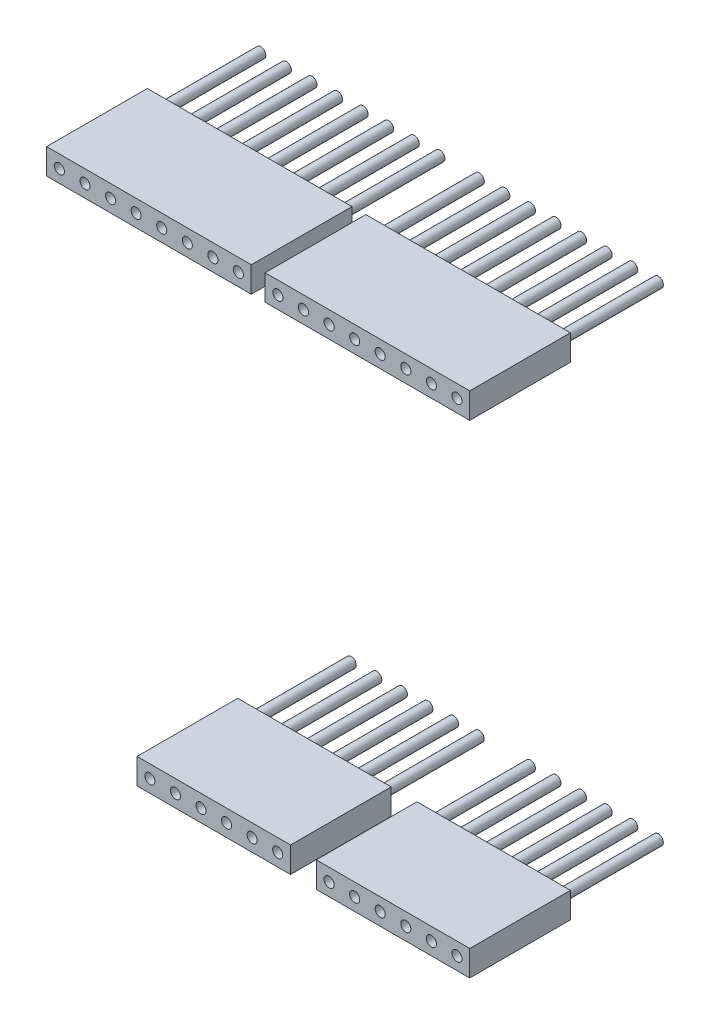
from build123d import *

# Parameters (mm, degrees)
SKETCH1_W              = 15.24
SKETCH1_H              = 2.54
SKETCH1_R              = 0.5
BOSS_EXTRUDE1_DEPTH    = 10
BOSS_EXTRUDE1_2_DEPTH  = 10
SKETCH1_W_2            = 20.32
BOSS_EXTRUDE1_3_DEPTH  = 10
BOSS_EXTRUDE1_4_DEPTH  = 10
SKETCH1_3_R            = 0.5
BOSS_EXTRUDE2_DEPTH    = 10
BOSS_EXTRUDE2_2_DEPTH  = 10
BOSS_EXTRUDE2_3_DEPTH  = 10
BOSS_EXTRUDE2_4_DEPTH  = 10
BOSS_EXTRUDE2_5_DEPTH  = 10
BOSS_EXTRUDE2_6_DEPTH  = 10
BOSS_EXTRUDE2_7_DEPTH  = 10
BOSS_EXTRUDE2_8_DEPTH  = 10
BOSS_EXTRUDE2_9_DEPTH  = 10
BOSS_EXTRUDE2_10_DEPTH = 10
BOSS_EXTRUDE2_11_DEPTH = 10
BOSS_EXTRUDE2_12_DEPTH = 10
BOSS_EXTRUDE2_13_DEPTH = 10
BOSS_EXTRUDE2_14_DEPTH = 10
BOSS_EXTRUDE2_15_DEPTH = 10
BOSS_EXTRUDE2_16_DEPTH = 10
BOSS_EXTRUDE2_17_DEPTH = 10
BOSS_EXTRUDE2_18_DEPTH = 10
BOSS_EXTRUDE2_19_DEPTH = 10
BOSS_EXTRUDE2_20_DEPTH = 10
BOSS_EXTRUDE2_21_DEPTH = 10
BOSS_EXTRUDE2_22_DEPTH = 10
BOSS_EXTRUDE2_23_DEPTH = 10
BOSS_EXTRUDE2_24_DEPTH = 10
BOSS_EXTRUDE2_25_DEPTH = 10
BOSS_EXTRUDE2_26_DEPTH = 10
BOSS_EXTRUDE2_27_DEPTH = 10
BOSS_EXTRUDE2_28_DEPTH = 10


with BuildPart() as part:
    # Sketch1 → Boss-Extrude1 (new body)
    with BuildSketch(Plane.XY):
        with Locations((38.3499995, 2.54)):
            Rectangle(SKETCH1_W, SKETCH1_H)
        with Locations((31.9999995, 2.54)):
            Circle(SKETCH1_R, mode=Mode.SUBTRACT)
        with Locations((34.5399995, 2.54)):
            Circle(SKETCH1_R, mode=Mode.SUBTRACT)
        with Locations((37.0799995, 2.54)):
            Circle(SKETCH1_R, mode=Mode.SUBTRACT)
        with Locations((39.6199995, 2.54)):
            Circle(SKETCH1_R, mode=Mode.SUBTRACT)
        with Locations((42.1599995, 2.54)):
            Circle(SKETCH1_R, mode=Mode.SUBTRACT)
        with Locations((44.6999995, 2.54)):
            Circle(SKETCH1_R, mode=Mode.SUBTRACT)
    extrude(amount=BOSS_EXTRUDE1_DEPTH)


with BuildPart() as body_2:
    # Sketch1 → Boss-Extrude1 2 (new body)
    with BuildSketch(Plane.XY):
        with Locations((56.14999946, 2.54)):
            Rectangle(SKETCH1_W, SKETCH1_H)
        with Locations((49.79999946, 2.54)):
            Circle(SKETCH1_R, mode=Mode.SUBTRACT)
        with Locations((52.33999946, 2.54)):
            Circle(SKETCH1_R, mode=Mode.SUBTRACT)
        with Locations((54.87999946, 2.54)):
            Circle(SKETCH1_R, mode=Mode.SUBTRACT)
        with Locations((57.41999946, 2.54)):
            Circle(SKETCH1_R, mode=Mode.SUBTRACT)
        with Locations((59.95999946, 2.54)):
            Circle(SKETCH1_R, mode=Mode.SUBTRACT)
        with Locations((62.49999946, 2.54)):
            Circle(SKETCH1_R, mode=Mode.SUBTRACT)
    extrude(amount=BOSS_EXTRUDE1_2_DEPTH)


with BuildPart() as body_3:
    # Sketch1 → Boss-Extrude1 3 (new body)
    with BuildSketch(Plane.XY):
        with Locations((31.90999968, 50.5000006)):
            Rectangle(SKETCH1_W_2, SKETCH1_H)
        with Locations((23.01999968, 50.5000006)):
            Circle(SKETCH1_R, mode=Mode.SUBTRACT)
        with Locations((25.55999968, 50.5000006)):
            Circle(SKETCH1_R, mode=Mode.SUBTRACT)
        with Locations((28.09999968, 50.5000006)):
            Circle(SKETCH1_R, mode=Mode.SUBTRACT)
        with Locations((30.63999968, 50.5000006)):
            Circle(SKETCH1_R, mode=Mode.SUBTRACT)
        with Locations((33.17999968, 50.5000006)):
            Circle(SKETCH1_R, mode=Mode.SUBTRACT)
        with Locations((35.71999968, 50.5000006)):
            Circle(SKETCH1_R, mode=Mode.SUBTRACT)
        with Locations((38.25999968, 50.5000006)):
            Circle(SKETCH1_R, mode=Mode.SUBTRACT)
        with Locations((40.79999968, 50.5000006)):
            Circle(SKETCH1_R, mode=Mode.SUBTRACT)
    extrude(amount=BOSS_EXTRUDE1_3_DEPTH)


with BuildPart() as body_4:
    # Sketch1 → Boss-Extrude1 4 (new body)
    with BuildSketch(Plane.XY):
        with Locations((53.60999946, 50.5000006)):
            Rectangle(SKETCH1_W_2, SKETCH1_H)
        with Locations((44.71999946, 50.5000006)):
            Circle(SKETCH1_R, mode=Mode.SUBTRACT)
        with Locations((47.25999946, 50.5000006)):
            Circle(SKETCH1_R, mode=Mode.SUBTRACT)
        with Locations((49.79999946, 50.5000006)):
            Circle(SKETCH1_R, mode=Mode.SUBTRACT)
        with Locations((52.33999946, 50.5000006)):
            Circle(SKETCH1_R, mode=Mode.SUBTRACT)
        with Locations((54.87999946, 50.5000006)):
            Circle(SKETCH1_R, mode=Mode.SUBTRACT)
        with Locations((57.41999946, 50.5000006)):
            Circle(SKETCH1_R, mode=Mode.SUBTRACT)
        with Locations((59.95999946, 50.5000006)):
            Circle(SKETCH1_R, mode=Mode.SUBTRACT)
        with Locations((62.49999946, 50.5000006)):
            Circle(SKETCH1_R, mode=Mode.SUBTRACT)
    extrude(amount=BOSS_EXTRUDE1_4_DEPTH)


with BuildPart() as body_5:
    # Sketch1_3 → Boss-Extrude2 (new body)
    with BuildSketch(Plane.XY):
        with Locations((23.01999968, 50.5000006)):
            Circle(SKETCH1_3_R)
    extrude(amount=-BOSS_EXTRUDE2_DEPTH)


with BuildPart() as body_6:
    # Sketch1_3 → Boss-Extrude2 2 (new body)
    with BuildSketch(Plane.XY):
        with Locations((25.55999968, 50.5000006)):
            Circle(SKETCH1_3_R)
    extrude(amount=-BOSS_EXTRUDE2_2_DEPTH)


with BuildPart() as body_7:
    # Sketch1_3 → Boss-Extrude2 3 (new body)
    with BuildSketch(Plane.XY):
        with Locations((28.09999968, 50.5000006)):
            Circle(SKETCH1_3_R)
    extrude(amount=-BOSS_EXTRUDE2_3_DEPTH)


with BuildPart() as body_8:
    # Sketch1_3 → Boss-Extrude2 4 (new body)
    with BuildSketch(Plane.XY):
        with Locations((30.63999968, 50.5000006)):
            Circle(SKETCH1_3_R)
    extrude(amount=-BOSS_EXTRUDE2_4_DEPTH)


with BuildPart() as body_9:
    # Sketch1_3 → Boss-Extrude2 5 (new body)
    with BuildSketch(Plane.XY):
        with Locations((33.17999968, 50.5000006)):
            Circle(SKETCH1_3_R)
    extrude(amount=-BOSS_EXTRUDE2_5_DEPTH)


with BuildPart() as body_10:
    # Sketch1_3 → Boss-Extrude2 6 (new body)
    with BuildSketch(Plane.XY):
        with Locations((35.71999968, 50.5000006)):
            Circle(SKETCH1_3_R)
    extrude(amount=-BOSS_EXTRUDE2_6_DEPTH)


with BuildPart() as body_11:
    # Sketch1_3 → Boss-Extrude2 7 (new body)
    with BuildSketch(Plane.XY):
        with Locations((38.25999968, 50.5000006)):
            Circle(SKETCH1_3_R)
    extrude(amount=-BOSS_EXTRUDE2_7_DEPTH)


with BuildPart() as body_12:
    # Sketch1_3 → Boss-Extrude2 8 (new body)
    with BuildSketch(Plane.XY):
        with Locations((40.79999968, 50.5000006)):
            Circle(SKETCH1_3_R)
    extrude(amount=-BOSS_EXTRUDE2_8_DEPTH)


with BuildPart() as body_13:
    # Sketch1_3 → Boss-Extrude2 9 (new body)
    with BuildSketch(Plane.XY):
        with Locations((44.71999946, 50.5000006)):
            Circle(SKETCH1_3_R)
    extrude(amount=-BOSS_EXTRUDE2_9_DEPTH)


with BuildPart() as body_14:
    # Sketch1_3 → Boss-Extrude2 10 (new body)
    with BuildSketch(Plane.XY):
        with Locations((31.9999995, 2.54)):
            Circle(SKETCH1_3_R)
    extrude(amount=-BOSS_EXTRUDE2_10_DEPTH)


with BuildPart() as body_15:
    # Sketch1_3 → Boss-Extrude2 11 (new body)
    with BuildSketch(Plane.XY):
        with Locations((49.79999946, 2.54)):
            Circle(SKETCH1_3_R)
    extrude(amount=-BOSS_EXTRUDE2_11_DEPTH)


with BuildPart() as body_16:
    # Sketch1_3 → Boss-Extrude2 12 (new body)
    with BuildSketch(Plane.XY):
        with Locations((47.25999946, 50.5000006)):
            Circle(SKETCH1_3_R)
    extrude(amount=-BOSS_EXTRUDE2_12_DEPTH)


with BuildPart() as body_17:
    # Sketch1_3 → Boss-Extrude2 13 (new body)
    with BuildSketch(Plane.XY):
        with Locations((49.79999946, 50.5000006)):
            Circle(SKETCH1_3_R)
    extrude(amount=-BOSS_EXTRUDE2_13_DEPTH)


with BuildPart() as body_18:
    # Sketch1_3 → Boss-Extrude2 14 (new body)
    with BuildSketch(Plane.XY):
        with Locations((52.33999946, 50.5000006)):
            Circle(SKETCH1_3_R)
    extrude(amount=-BOSS_EXTRUDE2_14_DEPTH)


with BuildPart() as body_19:
    # Sketch1_3 → Boss-Extrude2 15 (new body)
    with BuildSketch(Plane.XY):
        with Locations((54.87999946, 50.5000006)):
            Circle(SKETCH1_3_R)
    extrude(amount=-BOSS_EXTRUDE2_15_DEPTH)


with BuildPart() as body_20:
    # Sketch1_3 → Boss-Extrude2 16 (new body)
    with BuildSketch(Plane.XY):
        with Locations((57.41999946, 50.5000006)):
            Circle(SKETCH1_3_R)
    extrude(amount=-BOSS_EXTRUDE2_16_DEPTH)


with BuildPart() as body_21:
    # Sketch1_3 → Boss-Extrude2 17 (new body)
    with BuildSketch(Plane.XY):
        with Locations((59.95999946, 50.5000006)):
            Circle(SKETCH1_3_R)
    extrude(amount=-BOSS_EXTRUDE2_17_DEPTH)


with BuildPart() as body_22:
    # Sketch1_3 → Boss-Extrude2 18 (new body)
    with BuildSketch(Plane.XY):
        with Locations((62.49999946, 50.5000006)):
            Circle(SKETCH1_3_R)
    extrude(amount=-BOSS_EXTRUDE2_18_DEPTH)


with BuildPart() as body_23:
    # Sketch1_3 → Boss-Extrude2 19 (new body)
    with BuildSketch(Plane.XY):
        with Locations((34.5399995, 2.54)):
            Circle(SKETCH1_3_R)
    extrude(amount=-BOSS_EXTRUDE2_19_DEPTH)


with BuildPart() as body_24:
    # Sketch1_3 → Boss-Extrude2 20 (new body)
    with BuildSketch(Plane.XY):
        with Locations((52.33999946, 2.54)):
            Circle(SKETCH1_3_R)
    extrude(amount=-BOSS_EXTRUDE2_20_DEPTH)


with BuildPart() as body_25:
    # Sketch1_3 → Boss-Extrude2 21 (new body)
    with BuildSketch(Plane.XY):
        with Locations((37.0799995, 2.54)):
            Circle(SKETCH1_3_R)
    extrude(amount=-BOSS_EXTRUDE2_21_DEPTH)


with BuildPart() as body_26:
    # Sketch1_3 → Boss-Extrude2 22 (new body)
    with BuildSketch(Plane.XY):
        with Locations((54.87999946, 2.54)):
            Circle(SKETCH1_3_R)
    extrude(amount=-BOSS_EXTRUDE2_22_DEPTH)


with BuildPart() as body_27:
    # Sketch1_3 → Boss-Extrude2 23 (new body)
    with BuildSketch(Plane.XY):
        with Locations((39.6199995, 2.54)):
            Circle(SKETCH1_3_R)
    extrude(amount=-BOSS_EXTRUDE2_23_DEPTH)


with BuildPart() as body_28:
    # Sketch1_3 → Boss-Extrude2 24 (new body)
    with BuildSketch(Plane.XY):
        with Locations((57.41999946, 2.54)):
            Circle(SKETCH1_3_R)
    extrude(amount=-BOSS_EXTRUDE2_24_DEPTH)


with BuildPart() as body_29:
    # Sketch1_3 → Boss-Extrude2 25 (new body)
    with BuildSketch(Plane.XY):
        with Locations((42.1599995, 2.54)):
            Circle(SKETCH1_3_R)
    extrude(amount=-BOSS_EXTRUDE2_25_DEPTH)


with BuildPart() as body_30:
    # Sketch1_3 → Boss-Extrude2 26 (new body)
    with BuildSketch(Plane.XY):
        with Locations((59.95999946, 2.54)):
            Circle(SKETCH1_3_R)
    extrude(amount=-BOSS_EXTRUDE2_26_DEPTH)


with BuildPart() as body_31:
    # Sketch1_3 → Boss-Extrude2 27 (new body)
    with BuildSketch(Plane.XY):
        with Locations((44.6999995, 2.54)):
            Circle(SKETCH1_3_R)
    extrude(amount=-BOSS_EXTRUDE2_27_DEPTH)


with BuildPart() as body_32:
    # Sketch1_3 → Boss-Extrude2 28 (new body)
    with BuildSketch(Plane.XY):
        with Locations((62.49999946, 2.54)):
            Circle(SKETCH1_3_R)
    extrude(amount=-BOSS_EXTRUDE2_28_DEPTH)


solid = Compound([part.part, body_2.part, body_3.part, body_4.part, body_5.part, body_6.part, body_7.part, body_8.part, body_9.part, body_10.part, body_11.part, body_12.part, body_13.part, body_14.part, body_15.part, body_16.part, body_17.part, body_18.part, body_19.part, body_20.part, body_21.part, body_22.part, body_23.part, body_24.part, body_25.part, body_26.part, body_27.part, body_28.part, body_29.part, body_30.part, body_31.part, body_32.part])
